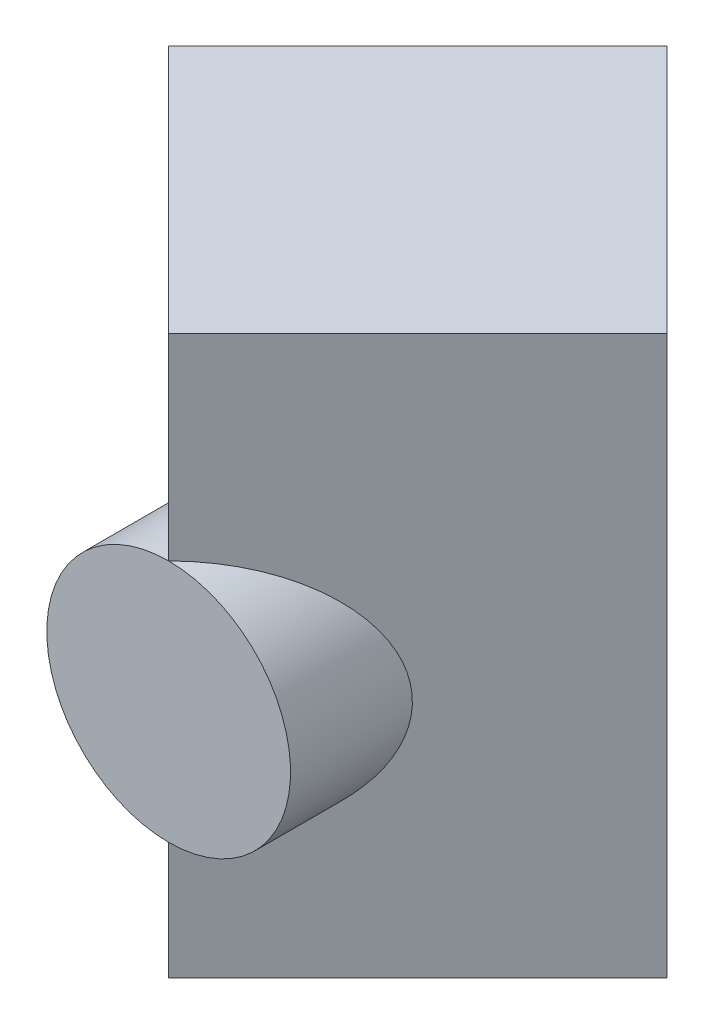
from build123d import *

# Parameters (mm, degrees)
BOSS_EXTRUDE1_DEPTH = 95
SKETCH3_R           = 41.5
BOSS_EXTRUDE3_DEPTH = 45


with BuildPart() as part:
    # Sketch2 → Boss-Extrude1 (new body, symmetric)
    with BuildSketch(Plane(origin=(0, 0, 0), x_dir=(1, 0, 0), z_dir=(0, 1, 0))):
        Polygon((-84.852813742, 0), (0, -84.852813742), (84.852813742, 0), (0, 84.852813742), align=None)
    extrude(amount=BOSS_EXTRUDE1_DEPTH, both=True)

    # Sketch3 → Boss-Extrude3 (add)
    with BuildSketch(Plane.XY.offset(84.852813742)):
        with Locations((0, -13.5)):
            Circle(SKETCH3_R)
    extrude(amount=-BOSS_EXTRUDE3_DEPTH)


solid = part.part
